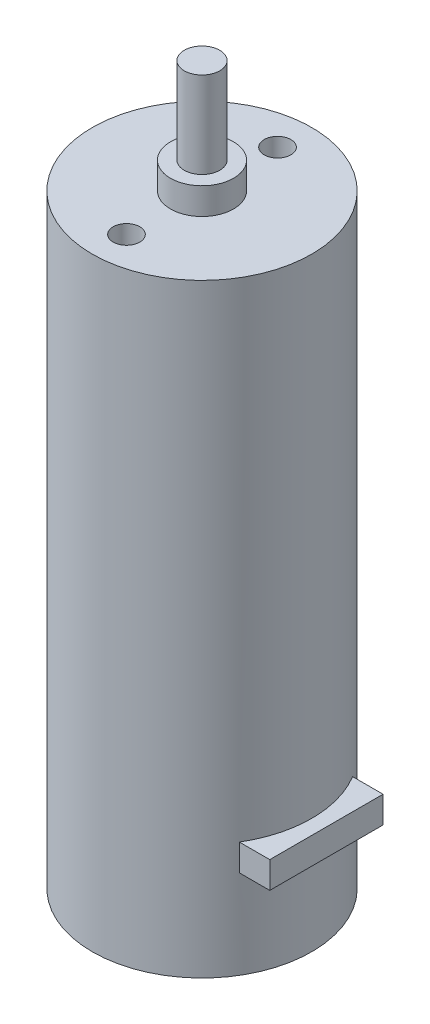
from build123d import *

# Parameters (mm, degrees)
SKETCH1_R           = 12.35
BOSS_EXTRUDE1_DEPTH = 68
SKETCH2_R           = 3.55
BOSS_EXTRUDE2_DEPTH = 3
SKETCH3_R           = 2
BOSS_EXTRUDE3_DEPTH = 9.7
SKETCH5_W           = 12.75
SKETCH5_H           = 3
BOSS_EXTRUDE4_DEPTH = 14
SKETCH4_R           = 1.5
CUT_EXTRUDE1_DEPTH  = 3


with BuildPart() as part:
    # Sketch1 → Boss-Extrude1 (new body)
    with BuildSketch(Plane(origin=(0, 0, 0), x_dir=(1, 0, 0), z_dir=(0, 1, 0))):
        Circle(SKETCH1_R)
    extrude(amount=BOSS_EXTRUDE1_DEPTH)

    # Sketch2 → Boss-Extrude2 (add)
    with BuildSketch(Plane(origin=(0, 68, 0), x_dir=(1, 0, 0), z_dir=(0, 1, 0))):
        Circle(SKETCH2_R)
    extrude(amount=BOSS_EXTRUDE2_DEPTH)

    # Sketch3 → Boss-Extrude3 (add)
    with BuildSketch(Plane(origin=(0, 71, 0), x_dir=(1, 0, 0), z_dir=(0, 1, 0))):
        Circle(SKETCH3_R)
    extrude(amount=BOSS_EXTRUDE3_DEPTH)

    # Sketch5 → Boss-Extrude4 (add)
    with BuildSketch(Plane(origin=(0, 0, 0), x_dir=(0, 0, -1), z_dir=(1, 0, 0))):
        with Locations((0, 11.5)):
            Rectangle(SKETCH5_W, SKETCH5_H)
    extrude(amount=BOSS_EXTRUDE4_DEPTH)

    # Sketch4 → Cut-Extrude1 (cut)
    with BuildSketch(Plane(origin=(0, 68, 0), x_dir=(1, 0, 0), z_dir=(0, 1, 0))):
        with Locations((0, 8.5)):
            Circle(SKETCH4_R)
        with Locations((0, -8.5)):
            Circle(SKETCH4_R)
    extrude(amount=-CUT_EXTRUDE1_DEPTH, mode=Mode.SUBTRACT)


solid = part.part
